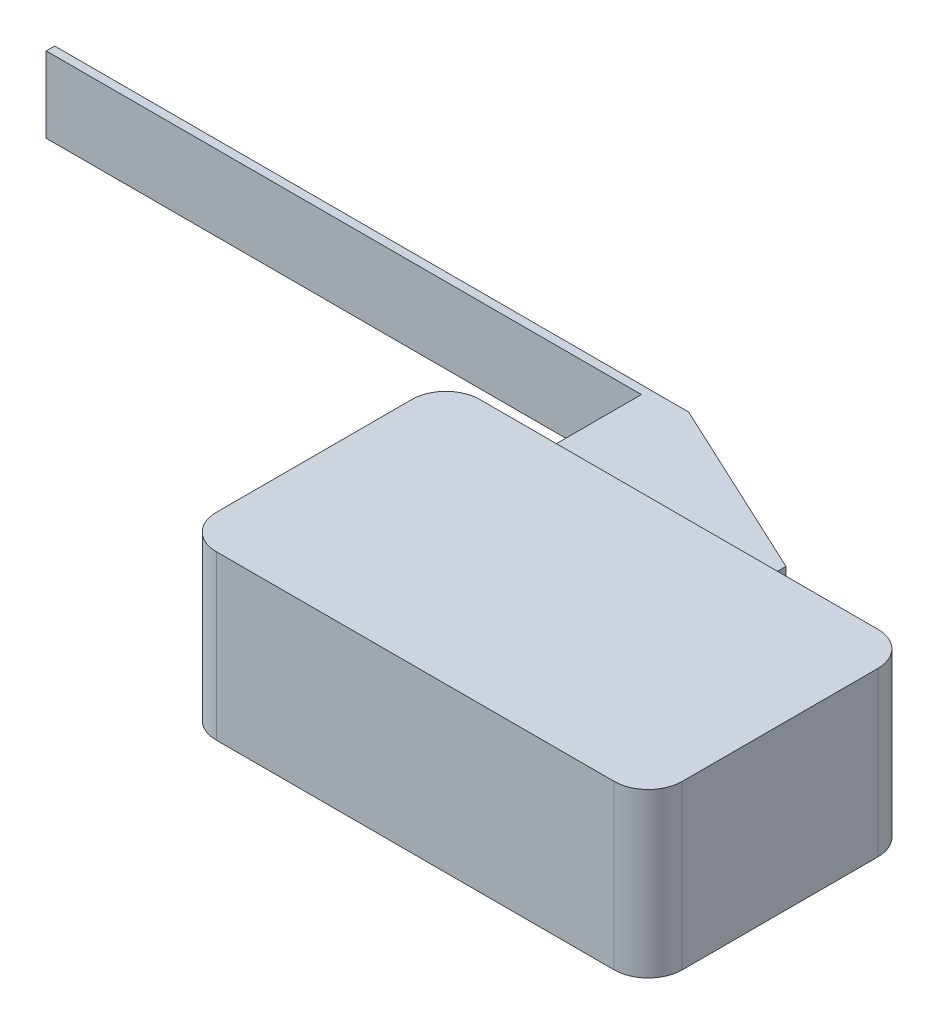
from build123d import *

# Parameters (mm, degrees)
SKETCH1_W           = 27.4
SKETCH1_H           = 15.5
BOSS_EXTRUDE1_DEPTH = 9.6
FILLET1_R           = 2
SKETCH2_W           = 13
SKETCH2_H           = 4.45
BOSS_EXTRUDE2_DEPTH = 8
SKETCH3_W           = 0.5
SKETCH3_H           = 4.45
BOSS_EXTRUDE3_DEPTH = 35
CHAMFER1_SIZE       = 5
CHAMFER1_SIZE2      = 10.722534603


with BuildPart() as part:
    # Sketch1 → Boss-Extrude1 (new body)
    with BuildSketch(Plane(origin=(0, 0, 0), x_dir=(1, 0, 0), z_dir=(0, 1, 0))):
        with Locations((13.7, 7.75)):
            Rectangle(SKETCH1_W, SKETCH1_H)
    extrude(amount=BOSS_EXTRUDE1_DEPTH)

    # Fillet1
    fillet1_edges = [part.edges().sort_by_distance(p)[0] for p in [
        (0, 4.8, -15.5),
        (27.4, 4.8, -15.5),
        (27.4, 4.8, 0),
        (0, 4.8, 0),
    ]]
    fillet(fillet1_edges, radius=FILLET1_R)

    # Sketch2 → Boss-Extrude2 (add)
    with BuildSketch(Plane(origin=(0, 0, -15.5), x_dir=(-1, 0, 0), z_dir=(0, 0, -1))):
        with Locations((-10.5, 4.875)):
            Rectangle(SKETCH2_W, SKETCH2_H)
    extrude(amount=BOSS_EXTRUDE2_DEPTH)

    # Sketch3 → Boss-Extrude3 (add)
    with BuildSketch(Plane.ZY.offset(-4)):
        with Locations((-23.25, 4.875)):
            Rectangle(SKETCH3_W, SKETCH3_H)
    extrude(amount=BOSS_EXTRUDE3_DEPTH)

    # Chamfer1
    chamfer1_edges = [part.edges().sort_by_distance(p)[0] for p in [
        (17, 4.875, -23.5),
    ]]
    chamfer1_side = [part.faces().sort_by_distance(p)[0] for p in [
        (17, 4.875, -19.5),
    ]]
    chamfer(chamfer1_edges, length=CHAMFER1_SIZE, length2=CHAMFER1_SIZE2, reference=chamfer1_side[0])


solid = part.part
